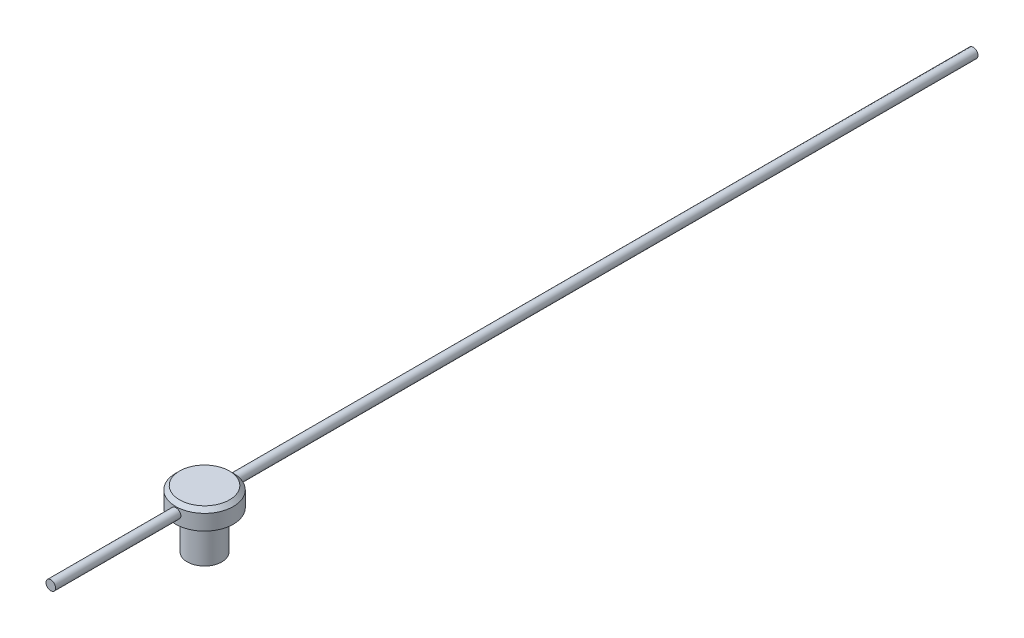
from build123d import *

# Parameters (mm, degrees)
SKETCH1_R                = 0.45
BOSS_EXTRUDE1_DEPTH      = 1
SKETCH2_R                = 0.75
BOSS_EXTRUDE2_DEPTH      = 0.5
SKETCH3_R                = 0.125
BOSS_EXTRUDE3_DEPTH      = 4
BOSS_EXTRUDE3_DEPTH_BACK = 20
CHAMFER1_SIZE            = 0.1


with BuildPart() as part:
    # Sketch1 → Boss-Extrude1 (new body)
    with BuildSketch(Plane(origin=(0, 0, 0), x_dir=(1, 0, 0), z_dir=(0, 1, 0))):
        Circle(SKETCH1_R)
    extrude(amount=BOSS_EXTRUDE1_DEPTH)

    # Sketch2 → Boss-Extrude2 (add)
    with BuildSketch(Plane(origin=(0, 1, 0), x_dir=(1, 0, 0), z_dir=(0, 1, 0))):
        Circle(SKETCH2_R)
    extrude(amount=BOSS_EXTRUDE2_DEPTH)

    # Sketch3 → Boss-Extrude3 (add, two sides)
    with BuildSketch(Plane.XY) as boss_extrude3_sk:
        with Locations((0, 1.25)):
            Circle(SKETCH3_R)
    extrude(amount=BOSS_EXTRUDE3_DEPTH)
    extrude(boss_extrude3_sk.sketch, amount=-BOSS_EXTRUDE3_DEPTH_BACK)

    # Chamfer1
    chamfer1_edges = [part.edges().sort_by_distance(p)[0] for p in [
        (-0.75, 1.5, 0),
    ]]
    chamfer(chamfer1_edges, length=CHAMFER1_SIZE)


solid = part.part
